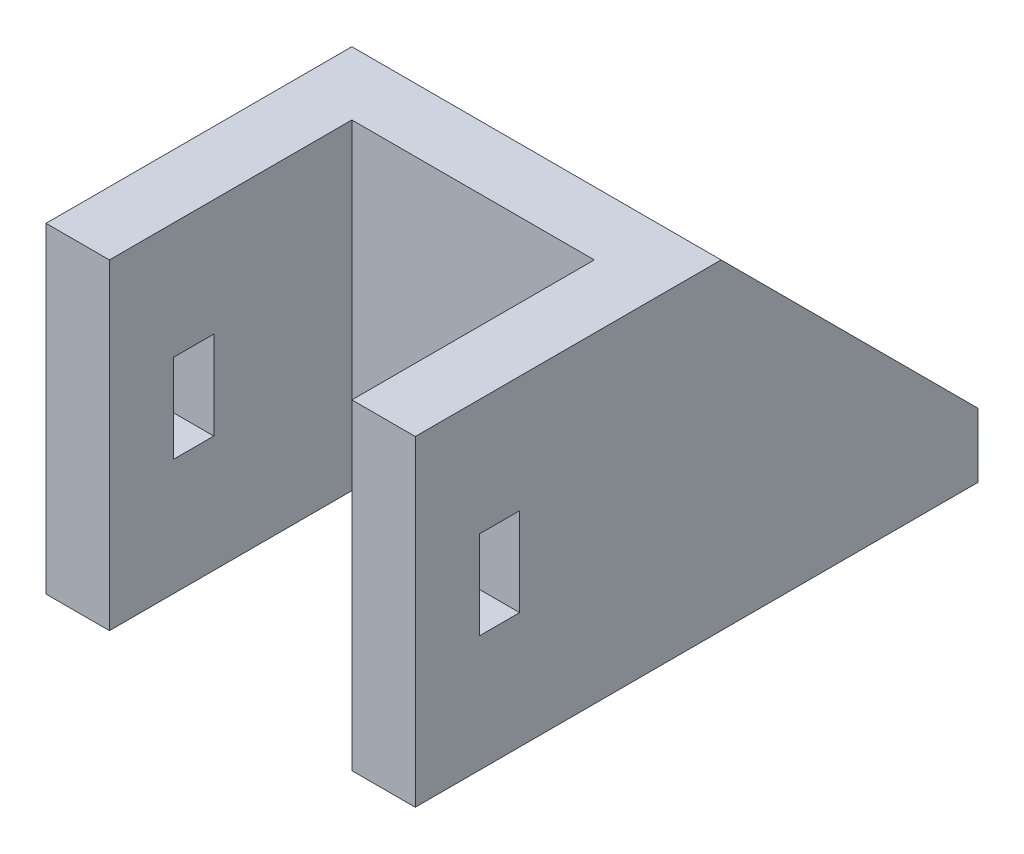
from build123d import *

# Parameters (mm, degrees)
EXTRUDE_1_DEPTH     = 4
EXTRUDE_2_DEPTH     = 16
EXTRUDE_3_DEPTH     = 4
EXTRUDE_4_DEPTH     = 4
SKETCH_5_W          = 2.5
SKETCH_5_H          = 5.5
CUT_EXTRUDE_1_DEPTH = 32


with BuildPart() as part:
    # 草图1 → 凸台-拉伸1 (new body)
    with BuildSketch(Plane(origin=(0, 0, 0), x_dir=(1, 0, 0), z_dir=(0, 1, 0))):
        Polygon((-4.794036697, 11.146788991), (-4.794036697, -7.903211009), (-0.844036697, -7.903211009), (-0.844036697, 7.196788991), (14.255963303, 7.196788991), (14.255963303, -7.903211009), (18.205963303, -7.903211009), (18.205963303, 11.146788991), (18.205963303, 27.146788991), (-4.794036697, 27.146788991), align=None)
    extrude(amount=EXTRUDE_1_DEPTH)

    # 草图2 → 凸台-拉伸2 (add)
    with BuildSketch(Plane(origin=(0, 4, 0), x_dir=(1, 0, 0), z_dir=(0, 1, 0))):
        Polygon((-4.794036697, 11.146788991), (-0.844036697, 11.146788991), (14.255963303, 11.146788991), (18.205963303, 11.146788991), (18.205963303, -7.903211009), (14.255963303, -7.903211009), (14.255963303, 7.196788991), (-0.844036697, 7.196788991), (-0.844036697, -7.903211009), (-4.794036697, -7.903211009), align=None)
    extrude(amount=EXTRUDE_2_DEPTH)

    # 草图4 → 凸台-拉伸4 (add)
    with BuildSketch(Plane(origin=(18.205963303, 0, 0), x_dir=(0, 0, -1), z_dir=(1, 0, 0))):
        Polygon((11.146788991, 20), (11.146788991, 4), (27.146788991, 4), align=None)
    extrude(amount=-EXTRUDE_4_DEPTH)

    # 草图5 → 切除-拉伸1 (cut)
    with BuildSketch(Plane(origin=(18.205963303, 0, 0), x_dir=(0, 0, -1), z_dir=(1, 0, 0))):
        with Locations((-2.653211009, 10)):
            Rectangle(SKETCH_5_W, SKETCH_5_H)
    extrude(amount=-CUT_EXTRUDE_1_DEPTH, mode=Mode.SUBTRACT)


with BuildPart() as body_2:
    # 草图3 → 凸台-拉伸3 (new body)
    with BuildSketch(Plane.ZY.offset(4.794036697)):
        Polygon((-11.146788991, 20), (-27.146788991, 4), (-11.146788991, 4), align=None)
    extrude(amount=-EXTRUDE_3_DEPTH)


solid = Compound([part.part, body_2.part])
